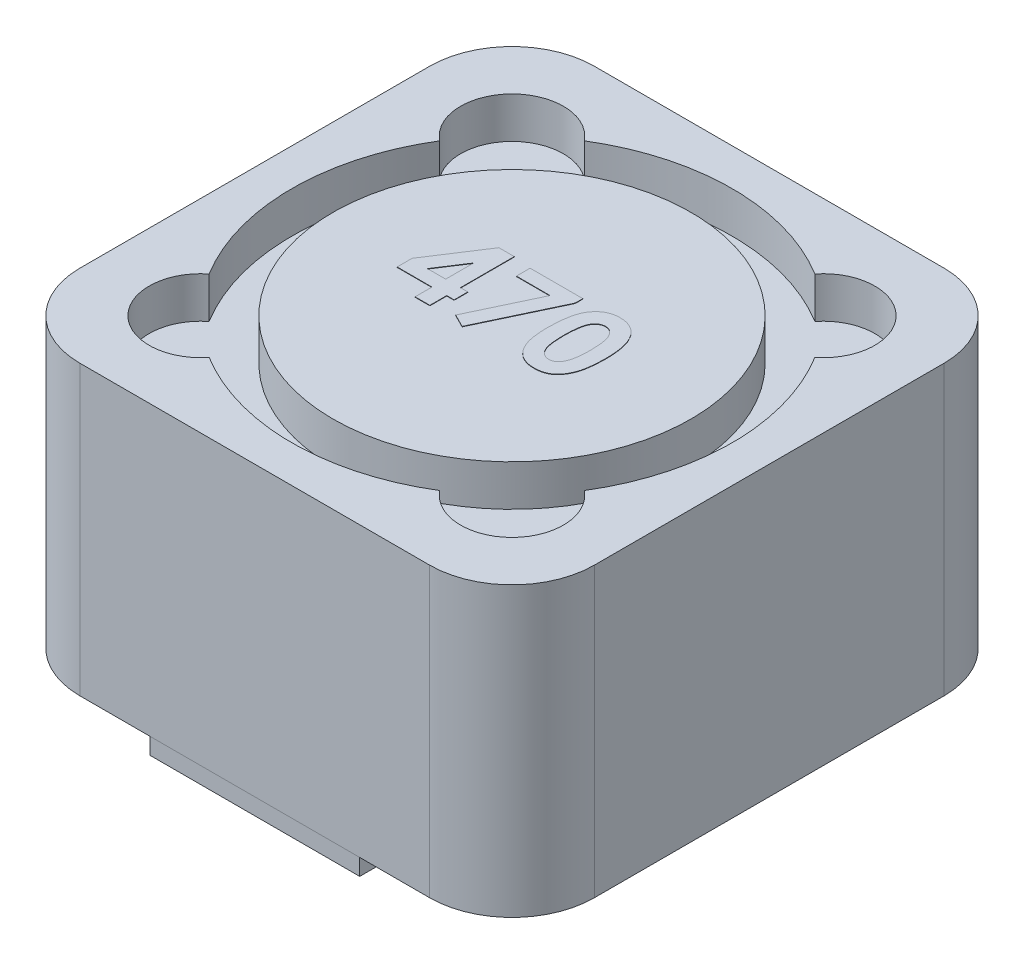
from build123d import *

# Parameters (mm, degrees)
SKETCH1_W             = 12.5
SKETCH1_H             = 12.5
BOSS_EXTRUDE1_DEPTH   = 7
SKETCH2_R             = 4.35
CUT_EXTRUDE1_DEPTH    = 1
SKETCH3_W             = 5.1
SKETCH3_H             = 0.8
BOSS_EXTRUDE2_DEPTH   = 0.4
BOSS_EXTRUDE2_2_DEPTH = 0.4
BOSS_EXTRUDE3_DEPTH   = 0.01
FILLET1_R             = 2


with BuildPart() as part:
    # Sketch1 → Boss-Extrude1 (new body)
    with BuildSketch(Plane(origin=(0, 0, 0), x_dir=(1, 0, 0), z_dir=(0, 1, 0))):
        Rectangle(SKETCH1_W, SKETCH1_H)
    extrude(amount=BOSS_EXTRUDE1_DEPTH)

    # Sketch2 → Cut-Extrude1 (cut)
    with BuildSketch(Plane(origin=(0, 7, 0), x_dir=(1, 0, 0), z_dir=(0, 1, 0))):
        with BuildLine():
            ThreePointArc((-4.557595229, 2.801932498), (-5.35, 0), (-4.557595229, -2.801932498))
            ThreePointArc((-4.557595229, -2.801932498), (-4.666904756, -4.666904756), (-2.801932498, -4.557595229))
            ThreePointArc((-2.801932498, -4.557595229), (0, -5.35), (2.801932498, -4.557595229))
            ThreePointArc((2.801932498, -4.557595229), (4.666904756, -4.666904756), (4.557595229, -2.801932498))
            ThreePointArc((4.557595229, -2.801932498), (5.35, 0), (4.557595229, 2.801932498))
            ThreePointArc((4.557595229, 2.801932498), (4.666904756, 4.666904756), (2.801932498, 4.557595229))
            ThreePointArc((2.801932498, 4.557595229), (0, 5.35), (-2.801932498, 4.557595229))
            ThreePointArc((-2.801932498, 4.557595229), (-4.666904756, 4.666904756), (-4.557595229, 2.801932498))
        make_face()
        Circle(SKETCH2_R, mode=Mode.SUBTRACT)
    extrude(amount=-CUT_EXTRUDE1_DEPTH, mode=Mode.SUBTRACT)

    # Sketch4 → Boss-Extrude3 (add)
    with BuildSketch(Plane(origin=(0, 7, 0), x_dir=(1, 0, 0), z_dir=(0, 1, 0))):
        Polygon((-1.580043076, 1.261031415), (-1.205844358, 1.261031415), (-1.205844358, -0.046660893), (-1.026357178, -0.046660893), (-1.026357178, -0.379994226), (-1.205844358, -0.379994226), (-1.205844358, -0.790250636), (-1.564818717, -0.790250636), (-1.564818717, -0.379994226), (-2.410972563, -0.379994226), (-2.410972563, -0.016612816), align=None)
        Polygon((-1.564818717, -0.046660893), (-1.564818717, 0.63402821), (-2.00752705, -0.046660893), align=None, mode=Mode.SUBTRACT)
        Polygon((-0.769946922, 1.209749364), (0.51210436, 1.209749364), (0.51210436, 1.023451287), (-0.370107178, -0.841532688), (-0.688216153, -0.681276277), (0.048963335, 0.87641603), (-0.769946922, 0.87641603), align=None)
        with BuildLine():
            add(Edge.make_bspline(
                [(1.365069104, 1.261031415), (1.382444953, 1.260773466), (1.416610514, 1.260266268), (1.466929955, 1.254772907), (1.515401489, 1.246473971), (1.562214743, 1.234899849), (1.60703275, 1.219581911), (1.650181705, 1.201246601), (1.69114801, 1.178932195), (1.730454117, 1.153726928), (1.768084886, 1.125190993), (1.803135886, 1.092658553), (1.836247224, 1.056878181), (1.866702161, 1.017308943), (1.895175131, 0.974310762), (1.921572577, 0.927876821), (1.945692419, 0.877779856), (1.967804983, 0.823929463), (1.987578108, 0.765518449), (2.004232987, 0.701876813), (2.018517333, 0.632990023), (2.030574328, 0.558686607), (2.039687468, 0.4788678), (2.045829907, 0.393586629), (2.05004514, 0.303007503), (2.050389158, 0.240870967), (2.050565899, 0.208948082)],
                knots=[0, 0, 0, 0, 5.2108e-05, 0.000102458, 0.00015166, 0.000199565, 0.000246949, 0.000293612, 0.000340039, 0.000386715, 0.000433592, 0.00048151, 0.000529994, 0.00057968, 0.000631128, 0.000684598, 0.000739788, 0.00079782, 0.00085914, 0.00092464, 0.000995043, 0.00107013, 0.001150388, 0.001235965, 0.001326599, 0.001422359, 0.001422359, 0.001422359, 0.001422359], degree=3))
            add(Edge.make_bspline(
                [(2.050565899, 0.208948082), (2.05037489, 0.176625805), (2.050003763, 0.113824201), (2.046005136, 0.022416592), (2.03911931, -0.063483771), (2.030244362, -0.143868003), (2.018088109, -0.218693654), (2.003851448, -0.288154471), (1.986933677, -0.352225278), (1.966509232, -0.410761708), (1.944530515, -0.464706674), (1.920344695, -0.514705961), (1.894373327, -0.560894997), (1.867212115, -0.603970605), (1.837371983, -0.642662938), (1.806305333, -0.678287739), (1.772659469, -0.709488012), (1.737851011, -0.737871679), (1.700604784, -0.762400864), (1.6613049, -0.783853685), (1.619250709, -0.80125447), (1.575208788, -0.816388744), (1.528428433, -0.827253519), (1.479652978, -0.835874362), (1.428331758, -0.840638768), (1.393390204, -0.841229824), (1.37548577, -0.841532688)],
                knots=[0, 0, 0, 0, 9.6963e-05, 0.000188397, 0.000274404, 0.000355458, 0.00043094, 0.000501736, 0.000568113, 0.000629563, 0.000687595, 0.000742785, 0.000796058, 0.000846513, 0.000895393, 0.000942506, 0.000988138, 0.001032876, 0.001077101, 0.001121738, 0.00116698, 0.001213477, 0.001261286, 0.001310883, 0.001361991, 0.001415701, 0.001415701, 0.001415701, 0.001415701], degree=3))
            add(Edge.make_bspline(
                [(1.37548577, -0.841532688), (1.35758182, -0.841223982), (1.322508245, -0.840619232), (1.271048247, -0.835909787), (1.222014307, -0.827218596), (1.174863844, -0.816305332), (1.129925019, -0.801287956), (1.086982352, -0.783366552), (1.046366033, -0.762047586), (1.007963604, -0.73746125), (0.971906181, -0.709267491), (0.937633432, -0.677767872), (0.905221169, -0.643042236), (0.875162465, -0.604701628), (0.846965044, -0.563257814), (0.820922961, -0.518237527), (0.797051866, -0.469706315), (0.774605068, -0.417596531), (0.755101642, -0.36078631), (0.737744498, -0.298768345), (0.723525982, -0.231025665), (0.7120905, -0.157580032), (0.702960418, -0.078587045), (0.696168686, 0.005991424), (0.692147848, 0.09619477), (0.691780614, 0.158196023), (0.69159154, 0.190117953)],
                knots=[0, 0, 0, 0, 5.371e-05, 0.000105217, 0.000154814, 0.000203012, 0.000250269, 0.000296775, 0.000342472, 0.000387704, 0.000433384, 0.000479604, 0.000527228, 0.000575721, 0.000625614, 0.000677496, 0.000731606, 0.00078779, 0.000847594, 0.000911653, 0.00098088, 0.001055113, 0.001134575, 0.001219384, 0.001309617, 0.001405378, 0.001405378, 0.001405378, 0.001405378], degree=3))
            add(Edge.make_bspline(
                [(0.69159154, 0.190117953), (0.69193403, 0.234470962), (0.692594869, 0.320050664), (0.700969509, 0.443688451), (0.713261357, 0.557970167), (0.73131517, 0.662704649), (0.753638459, 0.758279801), (0.782224594, 0.844066025), (0.814767829, 0.921250365), (0.842498846, 0.966974833), (0.85585436, 0.988996159)],
                knots=[0, 0, 0, 0, 0.000133035, 0.000256692, 0.000371592, 0.000477702, 0.000575362, 0.000665694, 0.000748763, 0.000825937, 0.000825937, 0.000825937, 0.000825937], degree=3))
            add(Edge.make_bspline(
                [(0.85585436, 0.988996159), (0.871383516, 1.010629902), (0.901746074, 1.052928134), (0.954835857, 1.108457806), (1.011873916, 1.1559495), (1.074031782, 1.194328438), (1.1403264, 1.224594071), (1.211326945, 1.245970347), (1.286771223, 1.258425162), (1.338580067, 1.260149691), (1.365069104, 1.261031415)],
                knots=[0, 0, 0, 0, 7.9808e-05, 0.00015604, 0.000229755, 0.000301908, 0.000374523, 0.00044778, 0.000523722, 0.000603172, 0.000603172, 0.000603172, 0.000603172], degree=3))
        make_face()
        with BuildLine():
            add(Edge.make_bspline(
                [(1.373883206, 0.902057056), (1.358175295, 0.901312532), (1.32737945, 0.89985287), (1.282693212, 0.887462401), (1.24055688, 0.868324653), (1.208504897, 0.845295365), (1.184514307, 0.823219031), (1.167751909, 0.803240667), (1.151587219, 0.780946252), (1.13730975, 0.755329755), (1.123828093, 0.727311606), (1.11065245, 0.69676462), (1.099851883, 0.662938496), (1.089240611, 0.626409298), (1.079944148, 0.586167091), (1.072155749, 0.541882939), (1.0651975, 0.493268857), (1.060344038, 0.440293005), (1.055819155, 0.383010807), (1.052575504, 0.321294661), (1.051219416, 0.255161217), (1.050788356, 0.209616096), (1.050565899, 0.186111543)],
                knots=[0, 0, 0, 0, 4.7046e-05, 9.2235e-05, 0.000138125, 0.000185258, 0.00020992, 0.000235776, 0.000263347, 0.000292418, 0.000323596, 0.000356634, 0.000392108, 0.000430025, 0.000470745, 0.000515932, 0.000564886, 0.000618026, 0.000675487, 0.000737269, 0.000803394, 0.000873912, 0.000873912, 0.000873912, 0.000873912], degree=3))
            add(Edge.make_bspline(
                [(1.050565899, 0.186111543), (1.050932037, 0.155660259), (1.051634134, 0.097267664), (1.055311391, 0.01329708), (1.062682146, -0.063122914), (1.071849878, -0.132510242), (1.084726332, -0.194414911), (1.099541526, -0.249422596), (1.117836973, -0.296832082), (1.138980887, -0.337329017), (1.162398725, -0.371779676), (1.187819818, -0.40106289), (1.214378669, -0.426420773), (1.242904267, -0.447018668), (1.273328557, -0.462803946), (1.305397553, -0.474158101), (1.339131634, -0.481108452), (1.362232385, -0.482072243), (1.373883206, -0.482558329)],
                knots=[0, 0, 0, 0, 9.136e-05, 0.00017519, 0.000252051, 0.000321629, 0.000385038, 0.000441612, 0.000492353, 0.000537155, 0.000578382, 0.000617015, 0.000653294, 0.000688318, 0.000722185, 0.000755765, 0.000790101, 0.00082504, 0.00082504, 0.00082504, 0.00082504], degree=3))
            add(Edge.make_bspline(
                [(1.373883206, -0.482558329), (1.385134208, -0.482225713), (1.407162271, -0.481574492), (1.43928412, -0.474889797), (1.469660823, -0.464021935), (1.498200663, -0.448648582), (1.525005723, -0.429099011), (1.549944996, -0.405287313), (1.572830397, -0.376976142), (1.586163535, -0.355965065), (1.593033847, -0.345138457)],
                knots=[0, 0, 0, 0, 3.3713e-05, 6.6007e-05, 9.7943e-05, 0.000130206, 0.000162902, 0.000197191, 0.000233358, 0.000271805, 0.000271805, 0.000271805, 0.000271805], degree=3))
            add(Edge.make_bspline(
                [(1.593033847, -0.345138457), (1.601122483, -0.330344242), (1.618083697, -0.299321975), (1.637711243, -0.246973055), (1.654232618, -0.187932125), (1.668452323, -0.122015445), (1.678177734, -0.048963031), (1.686553246, 0.030761886), (1.690592963, 0.117560768), (1.691250045, 0.177695347), (1.69159154, 0.208948082)],
                knots=[0, 0, 0, 0, 5.0532e-05, 0.000105961, 0.000167212, 0.000234396, 0.000308053, 0.000388183, 0.000474833, 0.000568597, 0.000568597, 0.000568597, 0.000568597], degree=3))
            add(Edge.make_bspline(
                [(1.69159154, 0.208948082), (1.691459628, 0.240472105), (1.69120572, 0.30115047), (1.686547248, 0.3882614), (1.680059969, 0.467822777), (1.670570952, 0.539656973), (1.658361608, 0.60393837), (1.643313545, 0.660662766), (1.625572998, 0.709941954), (1.604534824, 0.751726795), (1.581233739, 0.787238178), (1.556498926, 0.817704191), (1.530225796, 0.843715303), (1.502458286, 0.865369401), (1.472553708, 0.881914755), (1.441083278, 0.893597144), (1.40798248, 0.900664598), (1.385403049, 0.901586638), (1.373883206, 0.902057056)],
                knots=[0, 0, 0, 0, 9.4559e-05, 0.00018201, 0.000261629, 0.000333985, 0.00039928, 0.000457786, 0.000509883, 0.00055611, 0.00059778, 0.000637076, 0.000673622, 0.00070848, 0.000742374, 0.000775714, 0.000808873, 0.000843412, 0.000843412, 0.000843412, 0.000843412], degree=3))
        make_face(mode=Mode.SUBTRACT)
    extrude(amount=BOSS_EXTRUDE3_DEPTH)

    # Fillet1
    fillet1_edges = [part.edges().sort_by_distance(p)[0] for p in [
        (6.25, 3.5, 6.25),
        (-6.25, 3.5, 6.25),
        (-6.25, 3.5, -6.25),
        (6.25, 3.5, -6.25),
    ]]
    fillet(fillet1_edges, radius=FILLET1_R)


with BuildPart() as body_2:
    # Sketch3 → Boss-Extrude2 (new body)
    with BuildSketch(Plane.XZ):
        with Locations((0, 5.85)):
            Rectangle(SKETCH3_W, SKETCH3_H)
    extrude(amount=BOSS_EXTRUDE2_DEPTH)


with BuildPart() as body_3:
    # Sketch3 → Boss-Extrude2 2 (new body)
    with BuildSketch(Plane.XZ):
        with Locations((0, -5.85)):
            Rectangle(SKETCH3_W, SKETCH3_H)
    extrude(amount=BOSS_EXTRUDE2_2_DEPTH)


solid = Compound([part.part, body_2.part, body_3.part])
